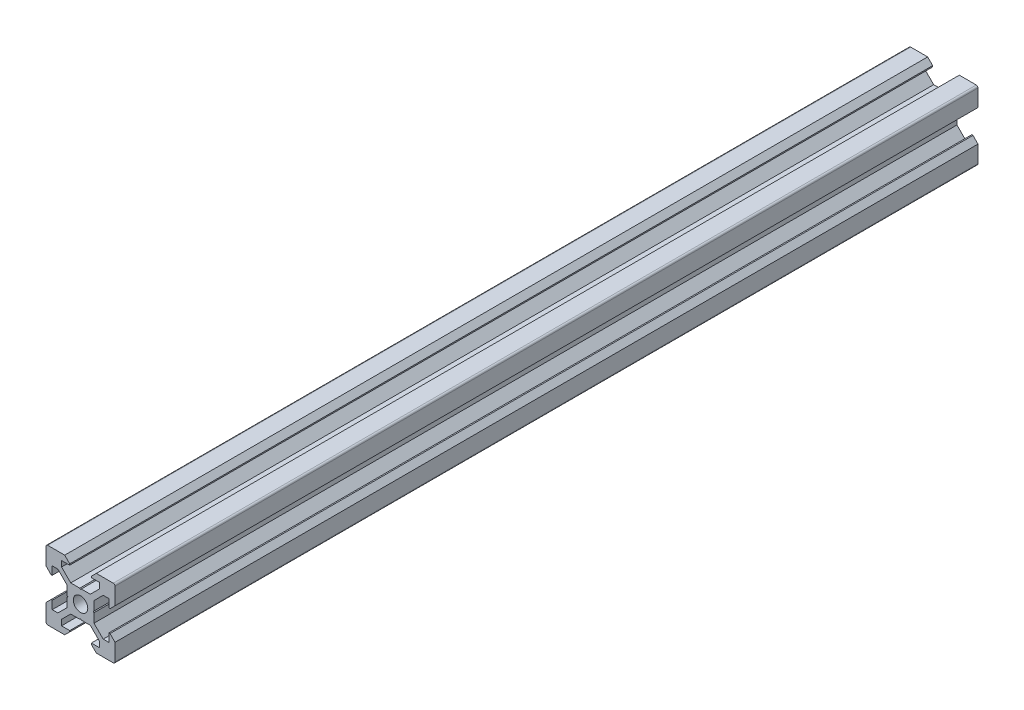
from build123d import *

# Parameters (mm, degrees)
SKETCH1_R           = 2.1
BOSS_EXTRUDE1_DEPTH = 250


with BuildPart() as part:
    # Sketch1 → Boss-Extrude1 (new body)
    with BuildSketch(Plane.XY):
        with BuildLine():
            Line((4.58, -10), (9.5, -10))
            ThreePointArc((9.5, -10), (9.853553391, -9.853553391), (10, -9.5))
            Line((10, -9.5), (10, -4.58))
            Line((10, -4.58), (8.545, -3.125))
            Line((8.545, -3.125), (8.2, -3.125))
            Line((8.2, -3.125), (8.2, -5.5))
            Line((8.2, -5.5), (6.560660172, -5.5))
            Line((6.560660172, -5.5), (3.9, -2.839339828))
            Line((3.9, -2.839339828), (3.9, -0.21))
            Line((3.9, -0.21), (3.69, 0))
            Line((3.69, 0), (3.9, 0.21))
            Line((3.9, 0.21), (3.9, 2.839339828))
            Line((3.9, 2.839339828), (6.560660172, 5.5))
            Line((6.560660172, 5.5), (8.2, 5.5))
            Line((8.2, 5.5), (8.2, 3.125))
            Line((8.2, 3.125), (8.545, 3.125))
            Line((8.545, 3.125), (10, 4.58))
            Line((10, 4.58), (10, 9.5))
            ThreePointArc((10, 9.5), (9.853553391, 9.853553391), (9.5, 10))
            Line((9.5, 10), (4.58, 10))
            Line((4.58, 10), (3.125, 8.545))
            Line((3.125, 8.545), (3.125, 8.2))
            Line((3.125, 8.2), (5.5, 8.2))
            Line((5.5, 8.2), (5.5, 6.560660172))
            Line((5.5, 6.560660172), (2.839339828, 3.9))
            Line((2.839339828, 3.9), (0.21, 3.9))
            Line((0.21, 3.9), (0, 3.69))
            Line((0, 3.69), (-0.21, 3.9))
            Line((-0.21, 3.9), (-2.839339828, 3.9))
            Line((-2.839339828, 3.9), (-5.5, 6.560660172))
            Line((-5.5, 6.560660172), (-5.5, 8.2))
            Line((-5.5, 8.2), (-3.125, 8.2))
            Line((-3.125, 8.2), (-3.125, 8.545))
            Line((-3.125, 8.545), (-4.58, 10))
            Line((-4.58, 10), (-9.5, 10))
            ThreePointArc((-9.5, 10), (-9.853553391, 9.853553391), (-10, 9.5))
            Line((-10, 9.5), (-10, 4.58))
            Line((-10, 4.58), (-8.545, 3.125))
            Line((-8.545, 3.125), (-8.2, 3.125))
            Line((-8.2, 3.125), (-8.2, 5.5))
            Line((-8.2, 5.5), (-6.560660172, 5.5))
            Line((-6.560660172, 5.5), (-3.9, 2.839339828))
            Line((-3.9, 2.839339828), (-3.9, 0.21))
            Line((-3.9, 0.21), (-3.69, 0))
            Line((-3.69, 0), (-3.9, -0.21))
            Line((-3.9, -0.21), (-3.9, -2.839339828))
            Line((-3.9, -2.839339828), (-6.560660172, -5.5))
            Line((-6.560660172, -5.5), (-8.2, -5.5))
            Line((-8.2, -5.5), (-8.2, -3.125))
            Line((-8.2, -3.125), (-8.545, -3.125))
            Line((-8.545, -3.125), (-10, -4.58))
            Line((-10, -4.58), (-10, -9.5))
            ThreePointArc((-10, -9.5), (-9.853553391, -9.853553391), (-9.5, -10))
            Line((-9.5, -10), (-4.58, -10))
            Line((-4.58, -10), (-3.125, -8.545))
            Line((-3.125, -8.545), (-3.125, -8.2))
            Line((-3.125, -8.2), (-5.5, -8.2))
            Line((-5.5, -8.2), (-5.5, -6.560660172))
            Line((-5.5, -6.560660172), (-2.839339828, -3.9))
            Line((-2.839339828, -3.9), (-0.21, -3.9))
            Line((-0.21, -3.9), (0, -3.69))
            Line((0, -3.69), (0.21, -3.9))
            Line((0.21, -3.9), (2.839339828, -3.9))
            Line((2.839339828, -3.9), (5.5, -6.560660172))
            Line((5.5, -6.560660172), (5.5, -8.2))
            Line((5.5, -8.2), (3.125, -8.2))
            Line((3.125, -8.2), (3.125, -8.545))
            Line((3.125, -8.545), (4.58, -10))
        make_face()
        Circle(SKETCH1_R, mode=Mode.SUBTRACT)
    extrude(amount=BOSS_EXTRUDE1_DEPTH)


solid = part.part
